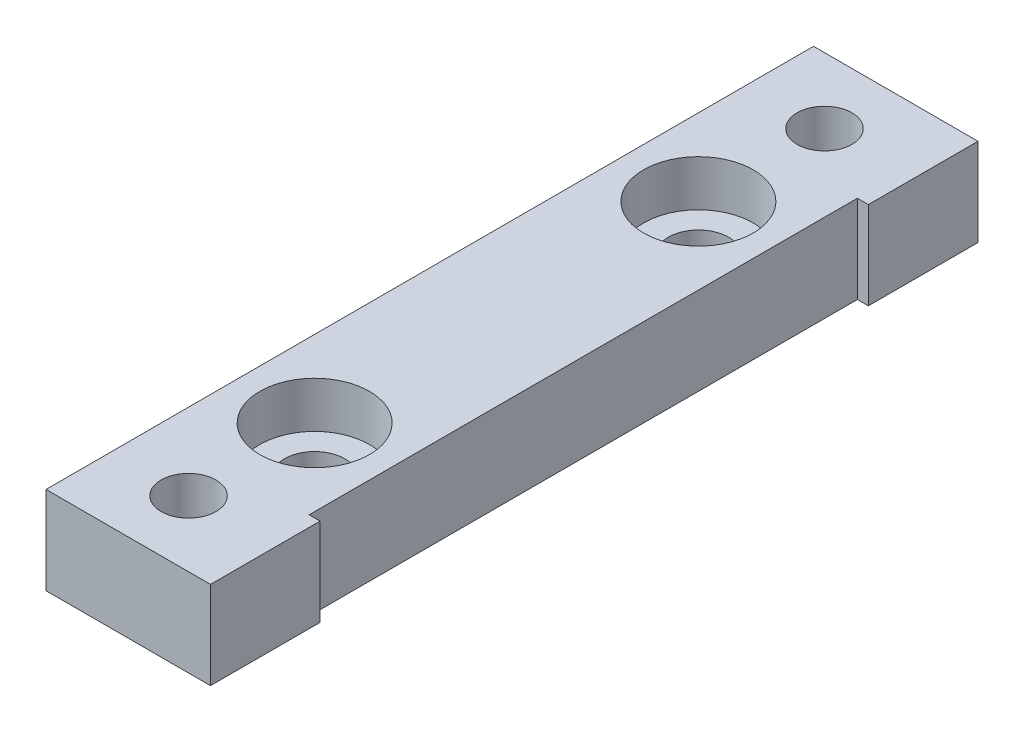
from build123d import *

# Parameters (mm, degrees)
SKETCH1_W           = 15
SKETCH1_H           = 70
BOSS_EXTRUDE1_DEPTH = 8
SKETCH2_W           = 1
SKETCH2_H           = 50
CUT_EXTRUDE1_DEPTH  = 8
SKETCH3_R           = 2.5
CUT_EXTRUDE2_DEPTH  = 8
SKETCH4_R           = 2.75
CUT_EXTRUDE3_DEPTH  = 8
SKETCH5_R           = 5
CUT_EXTRUDE4_DEPTH  = 4.2


with BuildPart() as part:
    # Sketch1 → Boss-Extrude1 (new body)
    with BuildSketch(Plane(origin=(0, 0, 0), x_dir=(1, 0, 0), z_dir=(0, 1, 0))):
        Rectangle(SKETCH1_W, SKETCH1_H)
    extrude(amount=BOSS_EXTRUDE1_DEPTH)

    # Sketch2 → Cut-Extrude1 (cut)
    with BuildSketch(Plane(origin=(0, 8, 0), x_dir=(1, 0, 0), z_dir=(0, 1, 0))):
        with Locations((7, 0)):
            Rectangle(SKETCH2_W, SKETCH2_H)
    extrude(amount=-CUT_EXTRUDE1_DEPTH, mode=Mode.SUBTRACT)

    # Sketch3 → Cut-Extrude2 (cut)
    with BuildSketch(Plane(origin=(0, 8, 0), x_dir=(1, 0, 0), z_dir=(0, 1, 0))):
        with Locations((-0.5, -29)):
            Circle(SKETCH3_R)
        with Locations((-0.5, 29)):
            Circle(SKETCH3_R)
    extrude(amount=-CUT_EXTRUDE2_DEPTH, mode=Mode.SUBTRACT)

    # Sketch4 → Cut-Extrude3 (cut)
    with BuildSketch(Plane(origin=(0, 8, 0), x_dir=(1, 0, 0), z_dir=(0, 1, 0))):
        with Locations((-0.5, -17.5)):
            Circle(SKETCH4_R)
        with Locations((-0.5, 17.5)):
            Circle(SKETCH4_R)
    extrude(amount=-CUT_EXTRUDE3_DEPTH, mode=Mode.SUBTRACT)

    # Sketch5 → Cut-Extrude4 (cut)
    with BuildSketch(Plane(origin=(0, 8, 0), x_dir=(1, 0, 0), z_dir=(0, 1, 0))):
        with Locations((-0.5, 17.5)):
            Circle(SKETCH5_R)
        with Locations((-0.5, -17.5)):
            Circle(SKETCH5_R)
    extrude(amount=-CUT_EXTRUDE4_DEPTH, mode=Mode.SUBTRACT)


solid = part.part
